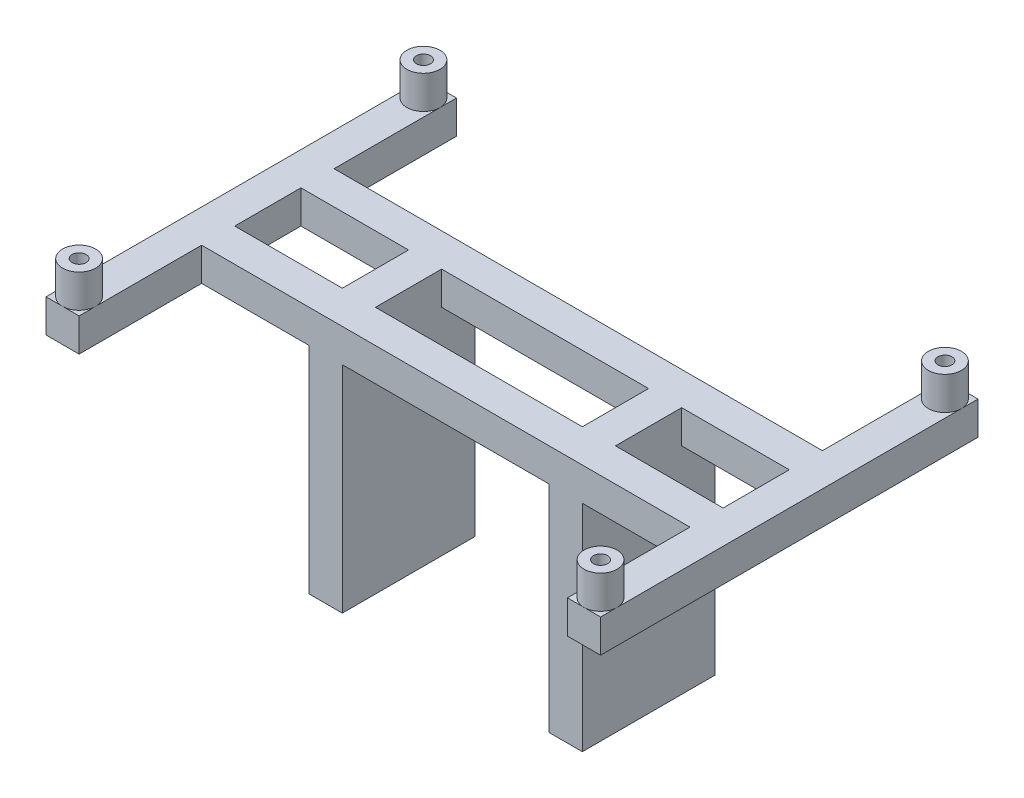
from build123d import *

# Parameters (mm, degrees)
SKETCH1_W           = 16.51
SKETCH1_H           = 10.16
SKETCH1_W_2         = 31.75
BOSS_EXTRUDE1_DEPTH = 5.08
SKETCH2_W           = 5.08
SKETCH2_H           = 20.32
BOSS_EXTRUDE2_DEPTH = 33.02
SKETCH4_R           = 2.54
SKETCH4_R_2         = 1.0795
BOSS_EXTRUDE3_DEPTH = 5.08
SKETCH5_R           = 1.0795
CUT_EXTRUDE1_DEPTH  = 39.1
SKETCH6_R           = 1.0795
CUT_EXTRUDE2_DEPTH  = 8.89


with BuildPart() as part:
    # Sketch1 → Boss-Extrude1 (new body)
    with BuildSketch(Plane(origin=(0, 0, 0), x_dir=(1, 0, 0), z_dir=(0, 1, 0))):
        Polygon((-42.545, 28.956), (-37.465, 28.956), (-37.465, 10.16), (37.465, 10.16), (37.465, 28.956), (42.545, 28.956), (42.545, -28.956), (37.465, -28.956), (37.465, -10.16), (-37.465, -10.16), (-37.465, -28.956), (-42.545, -28.956), align=None)
        with Locations((29.21, 0)):
            Rectangle(SKETCH1_W, SKETCH1_H, mode=Mode.SUBTRACT)
        with Locations((-29.21, 0)):
            Rectangle(SKETCH1_W, SKETCH1_H, mode=Mode.SUBTRACT)
        Rectangle(SKETCH1_W_2, SKETCH1_H, mode=Mode.SUBTRACT)
    extrude(amount=BOSS_EXTRUDE1_DEPTH)

    # Sketch2 → Boss-Extrude2 (add)
    with BuildSketch(Plane.XZ):
        with Locations((-18.415, 0)):
            Rectangle(SKETCH2_W, SKETCH2_H)
        with Locations((18.415, 0)):
            Rectangle(SKETCH2_W, SKETCH2_H)
    extrude(amount=BOSS_EXTRUDE2_DEPTH)

    # Sketch4 → Boss-Extrude3 (add)
    with BuildSketch(Plane(origin=(0, 5.08, 0), x_dir=(1, 0, 0), z_dir=(0, 1, 0))):
        with Locations((-40.005, 26.416)):
            Circle(SKETCH4_R)
        with Locations((-40.005, 26.416)):
            Circle(SKETCH4_R_2, mode=Mode.SUBTRACT)
        with Locations((-40.005, -26.416)):
            Circle(SKETCH4_R)
        with Locations((-40.005, -26.416)):
            Circle(SKETCH4_R_2, mode=Mode.SUBTRACT)
        with Locations((40.005, -26.416)):
            Circle(SKETCH4_R)
        with Locations((40.005, -26.416)):
            Circle(SKETCH4_R_2, mode=Mode.SUBTRACT)
        with Locations((40.005, 26.416)):
            Circle(SKETCH4_R)
        with Locations((40.005, 26.416)):
            Circle(SKETCH4_R_2, mode=Mode.SUBTRACT)
    extrude(amount=BOSS_EXTRUDE3_DEPTH)

    # Sketch5 → Cut-Extrude1 (cut, through all)
    with BuildSketch(Plane(origin=(0, 5.08, 0), x_dir=(1, 0, 0), z_dir=(0, 1, 0))):
        with Locations((-40.005, -26.416)):
            Circle(SKETCH5_R)
        with Locations((-40.005, 26.416)):
            Circle(SKETCH5_R)
        with Locations((40.005, 26.416)):
            Circle(SKETCH5_R)
        with Locations((40.005, -26.416)):
            Circle(SKETCH5_R)
    extrude(amount=-CUT_EXTRUDE1_DEPTH, mode=Mode.SUBTRACT)

    # Sketch6 → Cut-Extrude2 (cut)
    with BuildSketch(Plane.XZ.offset(33.02)):
        with Locations((-18.415, 7.62)):
            Circle(SKETCH6_R)
        with Locations((-18.415, -7.62)):
            Circle(SKETCH6_R)
        with Locations((18.415, 7.62)):
            Circle(SKETCH6_R)
        with Locations((18.415, -7.62)):
            Circle(SKETCH6_R)
    extrude(amount=-CUT_EXTRUDE2_DEPTH, mode=Mode.SUBTRACT)


solid = part.part
